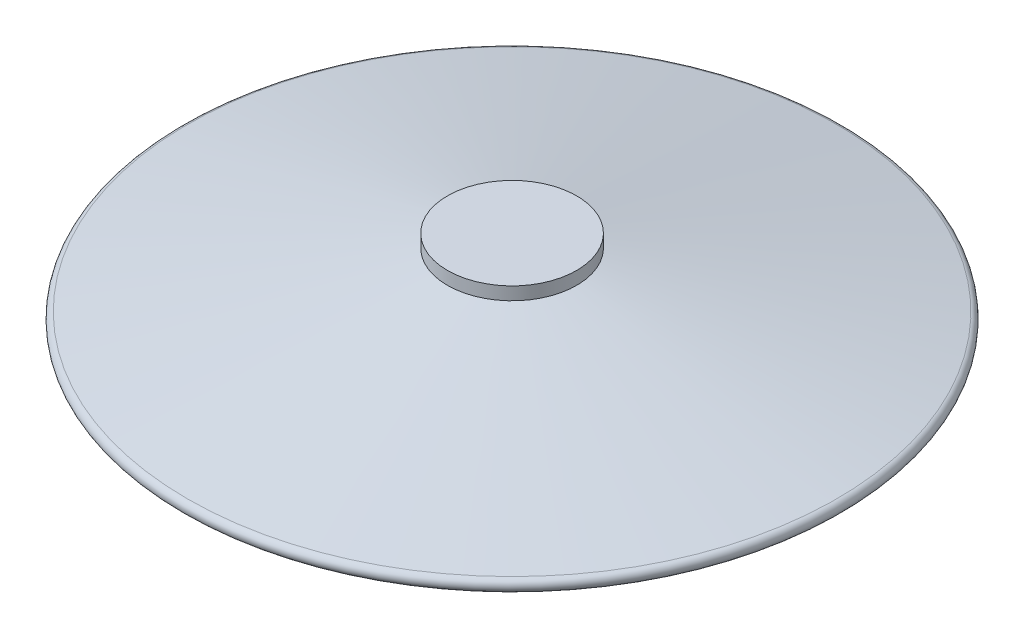
from build123d import *


with BuildPart() as part:
    # Sketch1 → Revolve1 (revolve)
    with BuildSketch(Plane.XY):
        with BuildLine():
            Line((0, 6.25), (-5, 6.25))
            Line((-5, 6.25), (-5, 5.25))
            Line((-5, 5.25), (-25.103669464, 0.989134585))
            ThreePointArc((-25.103669464, 0.989134585), (-25.497276227, 0.447881349), (-25, 0))
            Line((-25, 0), (0, 0))
            Line((0, 0), (0, 6.25))
        make_face()
    revolve(axis=Axis((0, 17.720157406, 0), (0, -1, 0)))


solid = part.part
